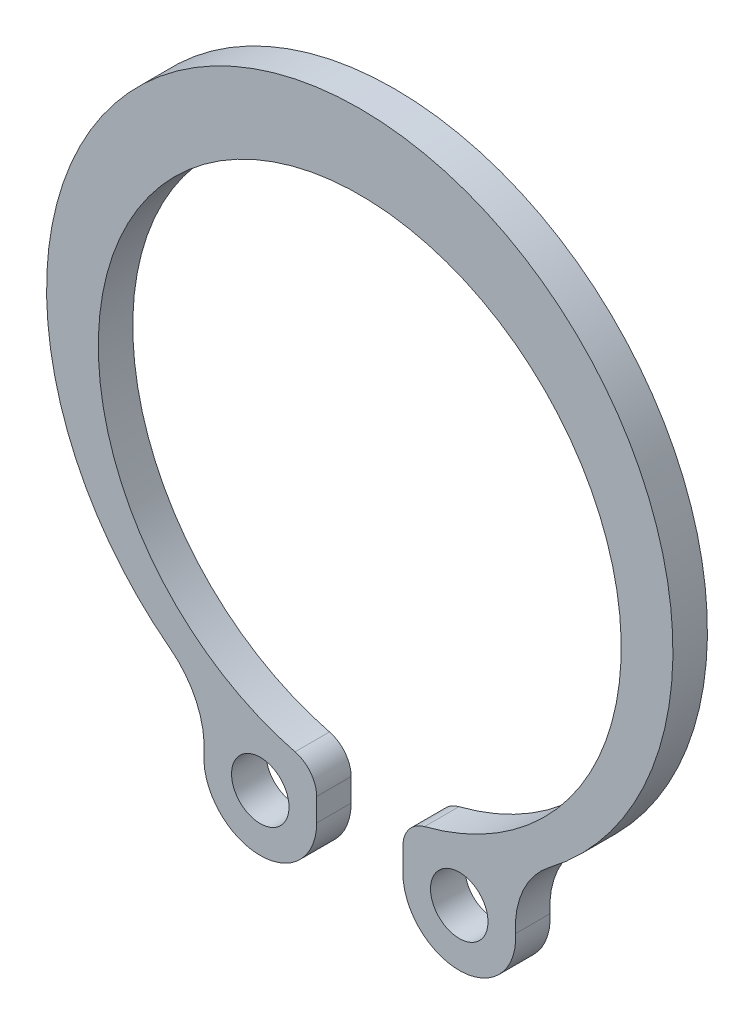
from build123d import *

# Parameters (mm, degrees)
SKETCH_1_R      = 1
EXTRUDE_1_DEPTH = 1.2


with BuildPart() as part:
    # Эскиз1 → Бобышка-Вытянуть1 (new body)
    with BuildSketch(Plane.XY):
        with BuildLine():
            Line((-1.5, -11.384990922), (-1.5, -10.585703858))
            ThreePointArc((-1.5, -10.585703858), (-1.710213715, -9.972321739), (-2.252475248, -9.616822288))
            ThreePointArc((-2.252475248, -9.616822288), (0, 8.3), (2.252475248, -9.616822288))
            ThreePointArc((2.252475248, -9.616822288), (1.710213715, -9.972321739), (1.5, -10.585703858))
            Line((1.5, -10.585703858), (1.5, -11.384990922))
            ThreePointArc((1.5, -11.384990922), (3.52665001, -13.346900966), (5.421753104, -11.257646183))
            ThreePointArc((5.421753104, -11.257646183), (5.685775429, -9.818447988), (6.599152829, -8.675320279))
            ThreePointArc((6.599152829, -8.675320279), (0, 10.9), (-6.599152829, -8.675320279))
            ThreePointArc((-6.599152829, -8.675320279), (-5.685775429, -9.818447988), (-5.421753104, -11.257646183))
            ThreePointArc((-5.421753104, -11.257646183), (-3.52665001, -13.346900966), (-1.5, -11.384990922))
        make_face()
        with Locations((-3.462944082, -11.384990922)):
            Circle(SKETCH_1_R, mode=Mode.SUBTRACT)
        with Locations((3.462944082, -11.384990922)):
            Circle(SKETCH_1_R, mode=Mode.SUBTRACT)
    extrude(amount=EXTRUDE_1_DEPTH)


solid = part.part
